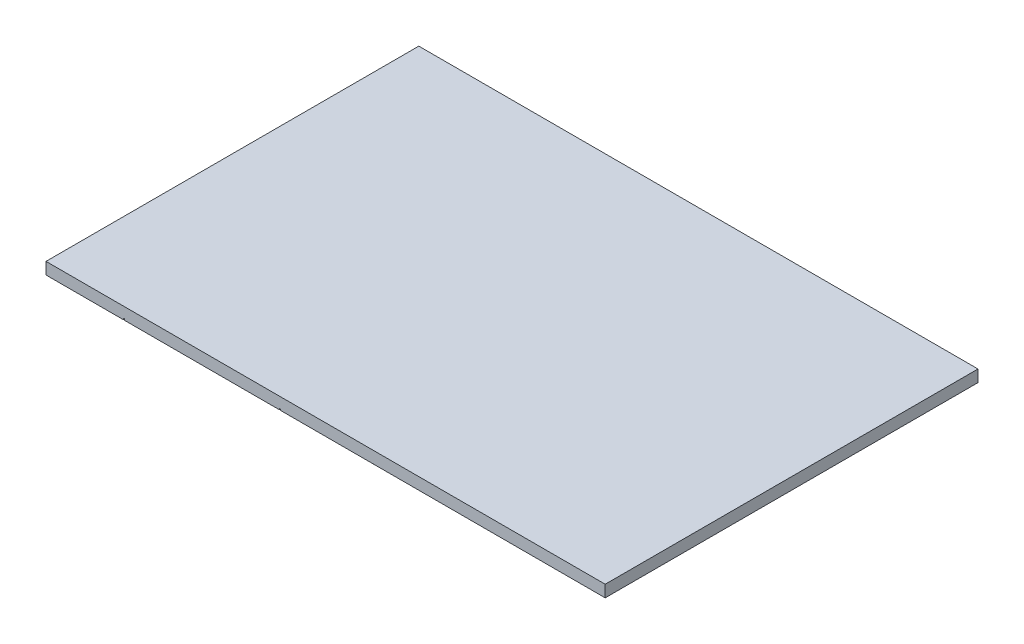
from build123d import *

# Parameters (mm, degrees)
SKETCH_1_W             = 129
SKETCH_1_H             = 86
EXTRUDE_2_DEPTH        = 2.73
CUT_EXTRUDE_1507_DEPTH = 1
SKETCH_1_7_RX          = 0.202164981
SKETCH_1_7_RY          = 0.2
CUT_EXTRUDE_5_DEPTH    = 0.3
CUT_EXTRUDE_15_DEPTH   = 0.3


with BuildPart() as part:
    # Эскиз1 → Бобышка-Вытянуть2 (new body)
    with BuildSketch(Plane(origin=(0, 0, 0), x_dir=(1, 0, 0), z_dir=(0, 1, 0))):
        with Locations((62.5, 41)):
            Rectangle(SKETCH_1_W, SKETCH_1_H)
    extrude(amount=EXTRUDE_2_DEPTH)

    # Эскиз1<4> → Cut-Extrude 1507 (cut)
    with BuildSketch(Plane(origin=(0, 0, 0), x_dir=(1, 0, 0), z_dir=(0, 1, 0))):
        with BuildLine():
            Line((6.5, -1.607315502), (6.5, 77.9))
            ThreePointArc((6.5, 77.9), (6.646446609, 78.253553391), (7, 78.4))
            Line((7, 78.4), (25, 78.4))
            ThreePointArc((25, 78.4), (25.353553391, 78.253553391), (25.5, 77.9))
            Line((25.5, 77.9), (25.5, 3.9))
            ThreePointArc((25.5, 3.9), (25.646446609, 3.546446609), (26, 3.4))
            Line((26, 3.4), (42, 3.4))
            ThreePointArc((42, 3.4), (42.353553391, 3.546446609), (42.5, 3.9))
            Line((42.5, 3.9), (42.5, 77.9))
            ThreePointArc((42.5, 77.9), (42.646446609, 78.253553391), (43, 78.4))
            Line((43, 78.4), (61, 78.4))
            ThreePointArc((61, 78.4), (61.353553391, 78.253553391), (61.5, 77.9))
            Line((61.5, 77.9), (61.5, 3.9))
            ThreePointArc((61.5, 3.9), (61.646446609, 3.546446609), (62, 3.4))
            Line((62, 3.4), (78, 3.4))
            ThreePointArc((78, 3.4), (78.353553391, 3.546446609), (78.5, 3.9))
            Line((78.5, 3.9), (78.5, 77.9))
            ThreePointArc((78.5, 77.9), (78.646446609, 78.253553391), (79, 78.4))
            Line((79, 78.4), (97, 78.4))
            ThreePointArc((97, 78.4), (97.353553391, 78.253553391), (97.5, 77.9))
            Line((97.5, 77.9), (97.5, 3.9))
            ThreePointArc((97.5, 3.9), (97.646446609, 3.546446609), (98, 3.4))
            Line((98, 3.4), (114, 3.4))
            ThreePointArc((114, 3.4), (114.353553391, 3.546446609), (114.5, 3.9))
            Line((114.5, 3.9), (114.5, 78.4))
            Line((114.5, 78.4), (114.5, 83))
            Line((114.5, 83), (115.5, 83))
            Line((115.5, 83), (115.5, 77.4))
            Line((115.5, 77.4), (115.5, 2.9))
            ThreePointArc((115.5, 2.9), (115.353553391, 2.546446609), (115, 2.4))
            Line((115, 2.4), (97, 2.4))
            ThreePointArc((97, 2.4), (96.646446609, 2.546446609), (96.5, 2.9))
            Line((96.5, 2.9), (96.5, 76.9))
            ThreePointArc((96.5, 76.9), (96.353553391, 77.253553391), (96, 77.4))
            Line((96, 77.4), (80, 77.4))
            ThreePointArc((80, 77.4), (79.646446609, 77.253553391), (79.5, 76.9))
            Line((79.5, 76.9), (79.5, 2.9))
            ThreePointArc((79.5, 2.9), (79.353553391, 2.546446609), (79, 2.4))
            Line((79, 2.4), (61, 2.4))
            ThreePointArc((61, 2.4), (60.646446609, 2.546446609), (60.5, 2.9))
            Line((60.5, 2.9), (60.5, 76.9))
            ThreePointArc((60.5, 76.9), (60.353553391, 77.253553391), (60, 77.4))
            Line((60, 77.4), (44, 77.4))
            ThreePointArc((44, 77.4), (43.646446609, 77.253553391), (43.5, 76.9))
            Line((43.5, 76.9), (43.5, 2.9))
            ThreePointArc((43.5, 2.9), (43.353553391, 2.546446609), (43, 2.4))
            Line((43, 2.4), (25, 2.4))
            ThreePointArc((25, 2.4), (24.646446609, 2.546446609), (24.5, 2.9))
            Line((24.5, 2.9), (24.5, 76.9))
            ThreePointArc((24.5, 76.9), (24.353553391, 77.253553391), (24, 77.4))
            Line((24, 77.4), (8, 77.4))
            ThreePointArc((8, 77.4), (7.646446609, 77.253553391), (7.5, 76.9))
            Line((7.5, 76.9), (7.5, -1.607315502))
            Line((7.5, -1.607315502), (6.5, -1.607315502))
        make_face()
    extrude(amount=CUT_EXTRUDE_1507_DEPTH, mode=Mode.SUBTRACT)

    # Эскиз1<7> → Вырез-Вытянуть5 (cut)
    with BuildSketch(Plane(origin=(0, 0, 0), x_dir=(1, 0, 0), z_dir=(0, 1, 0))):
        with Locations(Location((16, 41), (0, 0, 180))):
            Ellipse(SKETCH_1_7_RX, SKETCH_1_7_RY)
    extrude(amount=CUT_EXTRUDE_5_DEPTH, mode=Mode.SUBTRACT)

    # Эскиз9 → Вырез-Вытянуть15 (cut)
    with BuildSketch(Plane(origin=(0, 0, 0), x_dir=(1, 0, 0), z_dir=(0, 1, 0))):
        with BuildLine():
            Line((15.847835019, 40.868322065), (15.847835019, -2))
            Line((15.847835019, -2), (16.152164981, -2))
            Line((16.152164981, -2), (16.152164981, 40.868322065))
            add(Edge.make_bspline(
                [(16.152164981, 40.868322065), (16.344349714, 41.085676609), (16.071092366, 41.187225919), (15.797835019, 41.288775229), (15.797835019, 41)],
                knots=[2.422915364, 2.422915364, 2.422915364, 4.353050335, 4.353050335, 6.283185307, 6.283185307, 6.283185307], degree=2, weights=[1, 0.569361398, 1, 0.569361398, 1]))
            add(Edge.make_bspline(
                [(15.797835019, 41), (15.797835019, 40.924870403), (15.847835019, 40.868322065)],
                knots=[0, 0, 0, 0.71867729, 0.71867729, 0.71867729], degree=2, weights=[1, 0.936129597, 1]))
        make_face()
        with BuildLine():
            Line((70.664301479, 83), (70.364301479, 83))
            Line((70.364301479, 83), (70.335776261, 41.114151494))
            ThreePointArc((70.335776261, 41.114151494), (70.499931864, 40.800000012), (70.664301479, 41.114039572))
            Line((70.664301479, 41.114039572), (70.664301479, 83))
        make_face()
        with BuildLine():
            add(Edge.make_bspline(
                [(51.797835019, 41), (51.797835019, 40.924870403), (51.847835019, 40.868322065)],
                knots=[0, 0, 0, 0.71867729, 0.71867729, 0.71867729], degree=2, weights=[1, 0.936129597, 1]))
            Line((51.847835019, 40.868322065), (51.847835019, -2))
            Line((51.847835019, -2), (52.152164981, -2))
            Line((52.152164981, -2), (52.152164981, 40.868322065))
            add(Edge.make_bspline(
                [(52.152164981, 40.868322065), (52.344349714, 41.085676609), (52.071092366, 41.187225919), (51.797835019, 41.288775229), (51.797835019, 41)],
                knots=[2.422915364, 2.422915364, 2.422915364, 4.353050335, 4.353050335, 6.283185307, 6.283185307, 6.283185307], degree=2, weights=[1, 0.569361398, 1, 0.569361398, 1]))
        make_face()
    extrude(amount=CUT_EXTRUDE_15_DEPTH, mode=Mode.SUBTRACT)


solid = part.part
